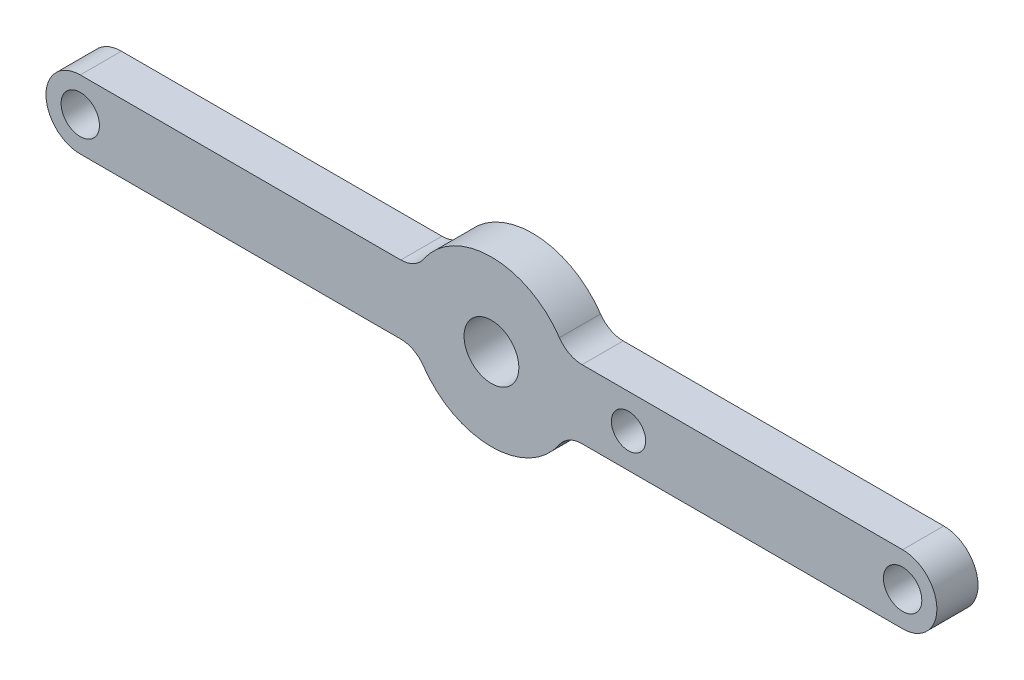
from build123d import *

# Parameters (mm, degrees)
ESBO_O1_R                = 2
ESBO_O1_R_2              = 1.25
RESSALTO_EXTRUS_O1_DEPTH = 3
ESBO_O6_R                = 1.4
CORTE_EXTRUS_O1_DEPTH    = 34.185087012


with BuildPart() as part:
    # Esboço1 → Ressalto-extrusão1 (new body)
    with BuildSketch(Plane.XY):
        with BuildLine():
            Line((6.614378278, 2.5), (30, 2.5))
            ThreePointArc((30, 2.5), (31.767766953, 1.767766953), (32.5, 0))
            ThreePointArc((32.5, 0), (31.767766953, -1.767766953), (30, -2.5))
            Line((30, -2.5), (6.614378278, -2.5))
            ThreePointArc((6.614378278, -2.5), (5.678963931, -2.732233047), (4.960783708, -3.375))
            ThreePointArc((4.960783708, -3.375), (0, -6), (-4.960783708, -3.375))
            ThreePointArc((-4.960783708, -3.375), (-5.678963931, -2.732233047), (-6.614378278, -2.5))
            Line((-6.614378278, -2.5), (-30, -2.5))
            ThreePointArc((-30, -2.5), (-31.767766953, -1.767766953), (-32.5, 0))
            ThreePointArc((-32.5, 0), (-31.767766953, 1.767766953), (-30, 2.5))
            Line((-30, 2.5), (-6.614378278, 2.5))
            ThreePointArc((-6.614378278, 2.5), (-5.678963931, 2.732233047), (-4.960783708, 3.375))
            ThreePointArc((-4.960783708, 3.375), (0, 6), (4.960783708, 3.375))
            ThreePointArc((4.960783708, 3.375), (5.678963931, 2.732233047), (6.614378278, 2.5))
        make_face()
        Circle(ESBO_O1_R, mode=Mode.SUBTRACT)
        with Locations((10, 0)):
            Circle(ESBO_O1_R_2, mode=Mode.SUBTRACT)
    extrude(amount=RESSALTO_EXTRUS_O1_DEPTH)

    # Esboço6 → Corte-extrusão1 (cut, symmetric)
    with BuildSketch(Plane(origin=(0, 0, 3), x_dir=(0, 1, 0), z_dir=(0, 0, 1))):
        with Locations((0, 30)):
            Circle(ESBO_O6_R)
    corte_extrus_o1 = extrude(amount=CORTE_EXTRUS_O1_DEPTH, both=True, mode=Mode.SUBTRACT)

    # Espelhar1: Corte-extrusão1 across plane
    add(corte_extrus_o1.mirror(Plane(origin=(0, 0, 0), x_dir=(0, 0, 1), z_dir=(1, 0, 0))), mode=Mode.SUBTRACT)


solid = part.part
